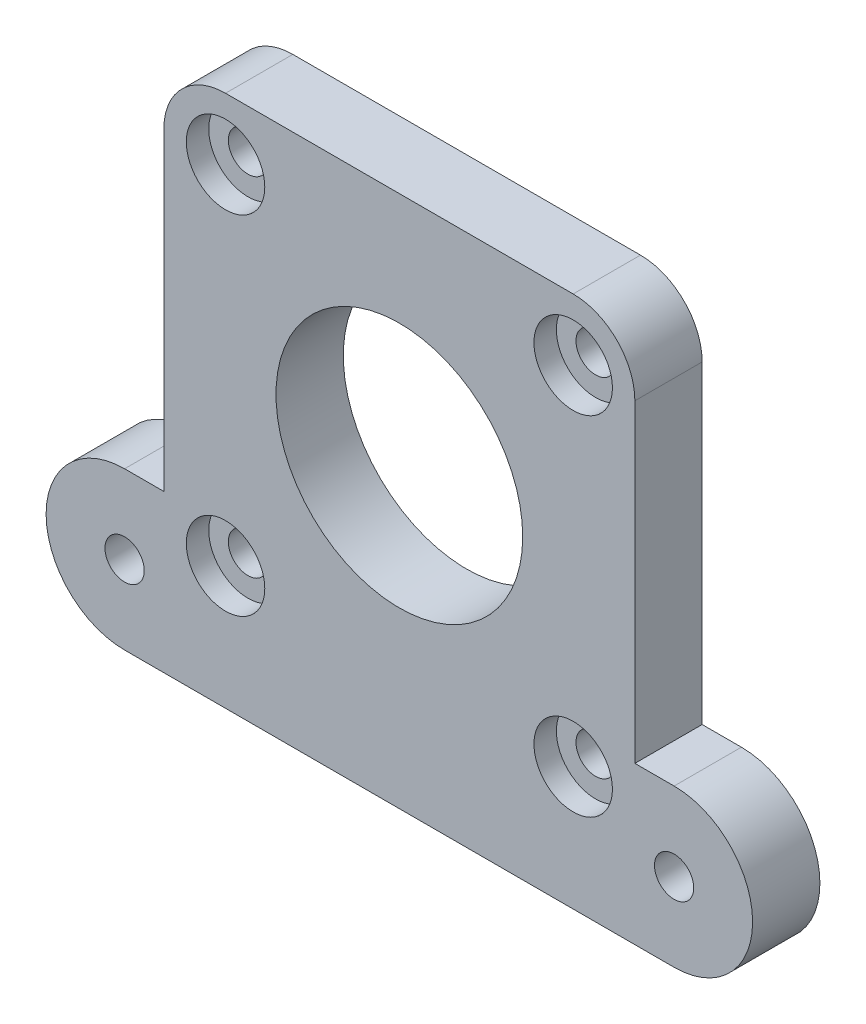
from build123d import *

# Parameters (mm, degrees)
ESBO_O1_R                = 1.75
ESBO_O1_R_2              = 11
RESSALTO_EXTRUS_O1_DEPTH = 6
FILETE1_R                = 5.5
ESBO_O2_R                = 3.5
CORTE_EXTRUS_O1_DEPTH    = 2


with BuildPart() as part:
    # Esboço1 → Ressalto-extrusão1 (new body)
    with BuildSketch(Plane.XY):
        with BuildLine():
            Line((-21, 23.75), (21, 23.75))
            Line((21, 23.75), (21, -9.75))
            Line((21, -9.75), (24.5, -9.75))
            ThreePointArc((24.5, -9.75), (31.5, -16.75), (24.5, -23.75))
            Line((24.5, -23.75), (21, -23.75))
            Line((21, -23.75), (-21, -23.75))
            Line((-21, -23.75), (-24.5, -23.75))
            ThreePointArc((-24.5, -23.75), (-31.5, -16.75), (-24.5, -9.75))
            Line((-24.5, -9.75), (-21, -9.75))
            Line((-21, -9.75), (-21, 23.75))
        make_face()
        with Locations((24.5, -16.75)):
            Circle(ESBO_O1_R, mode=Mode.SUBTRACT)
        with Locations((0, 2.75)):
            Circle(ESBO_O1_R_2, mode=Mode.SUBTRACT)
        with Locations((15.5, 18.25)):
            Circle(ESBO_O1_R, mode=Mode.SUBTRACT)
        with Locations((15.5, -12.75)):
            Circle(ESBO_O1_R, mode=Mode.SUBTRACT)
        with Locations((-15.5, 18.25)):
            Circle(ESBO_O1_R, mode=Mode.SUBTRACT)
        with Locations((-15.5, -12.75)):
            Circle(ESBO_O1_R, mode=Mode.SUBTRACT)
        with Locations((-24.5, -16.75)):
            Circle(ESBO_O1_R, mode=Mode.SUBTRACT)
    extrude(amount=RESSALTO_EXTRUS_O1_DEPTH)

    # Filete1
    filete1_edges = [part.edges().sort_by_distance(p)[0] for p in [
        (-21, 23.75, 3),
        (21, 23.75, 3),
    ]]
    fillet(filete1_edges, radius=FILETE1_R)

    # Esboço2 → Corte-extrusão1 (cut)
    with BuildSketch(Plane.XY.offset(6)):
        with Locations((-15.5, 18.25)):
            Circle(ESBO_O2_R)
        with Locations((15.5, 18.25)):
            Circle(ESBO_O2_R)
        with Locations((15.5, -12.75)):
            Circle(ESBO_O2_R)
        with Locations((-15.5, -12.75)):
            Circle(ESBO_O2_R)
    extrude(amount=-CORTE_EXTRUS_O1_DEPTH, mode=Mode.SUBTRACT)


solid = part.part
